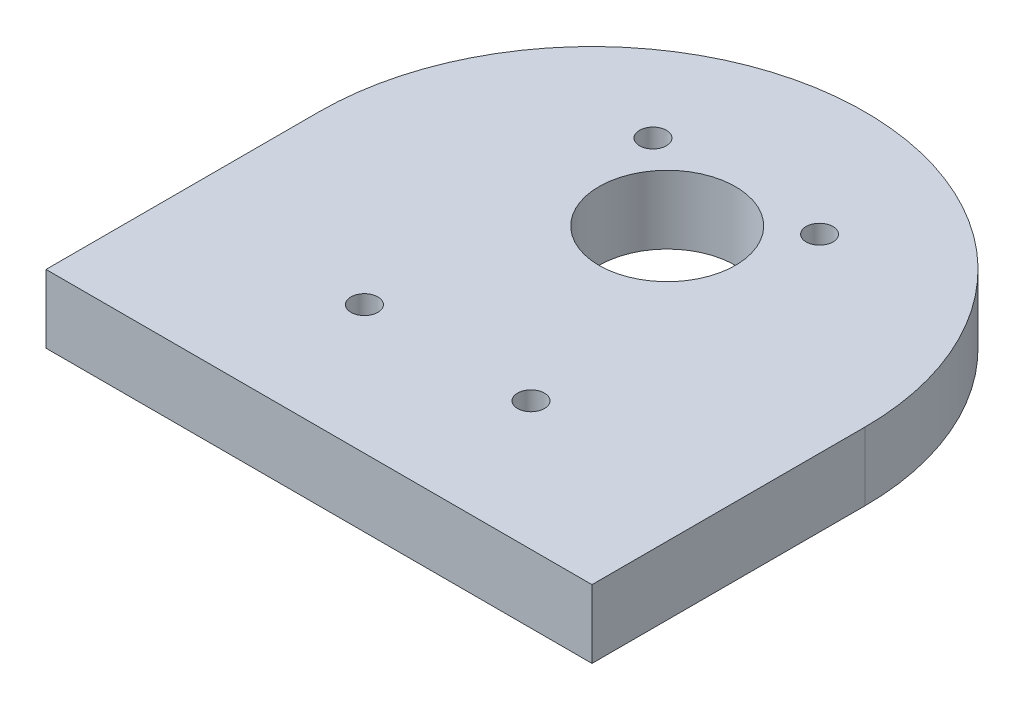
from build123d import *

# Parameters (mm, degrees)
SKETCH3_R           = 6.35
SKETCH3_R_2         = 1.25
BOSS_EXTRUDE4_DEPTH = 3.175


with BuildPart() as part:
    # Sketch3 → Boss-Extrude4 (new body, symmetric)
    with BuildSketch(Plane(origin=(0, 0, 0), x_dir=(1, 0, 0), z_dir=(0, 1, 0))):
        with BuildLine():
            Line((-25.4, 0), (-25.4, -25.4))
            Line((-25.4, -25.4), (0, -25.4))
            Line((0, -25.4), (25.4, -25.4))
            Line((25.4, -25.4), (25.4, 0))
            ThreePointArc((25.4, 0), (0, 25.4), (-25.4, 0))
        make_face()
        with Locations((1e-09, 7)):
            Circle(SKETCH3_R, mode=Mode.SUBTRACT)
        with Locations((7.75, 13.423393759)):
            Circle(SKETCH3_R_2, mode=Mode.SUBTRACT)
        with Locations((-7.75, 13.423393759)):
            Circle(SKETCH3_R_2, mode=Mode.SUBTRACT)
        with Locations((-7.75, -13.423393759)):
            Circle(SKETCH3_R_2, mode=Mode.SUBTRACT)
        with Locations((7.75, -13.423393759)):
            Circle(SKETCH3_R_2, mode=Mode.SUBTRACT)
    extrude(amount=BOSS_EXTRUDE4_DEPTH, both=True)


solid = part.part
